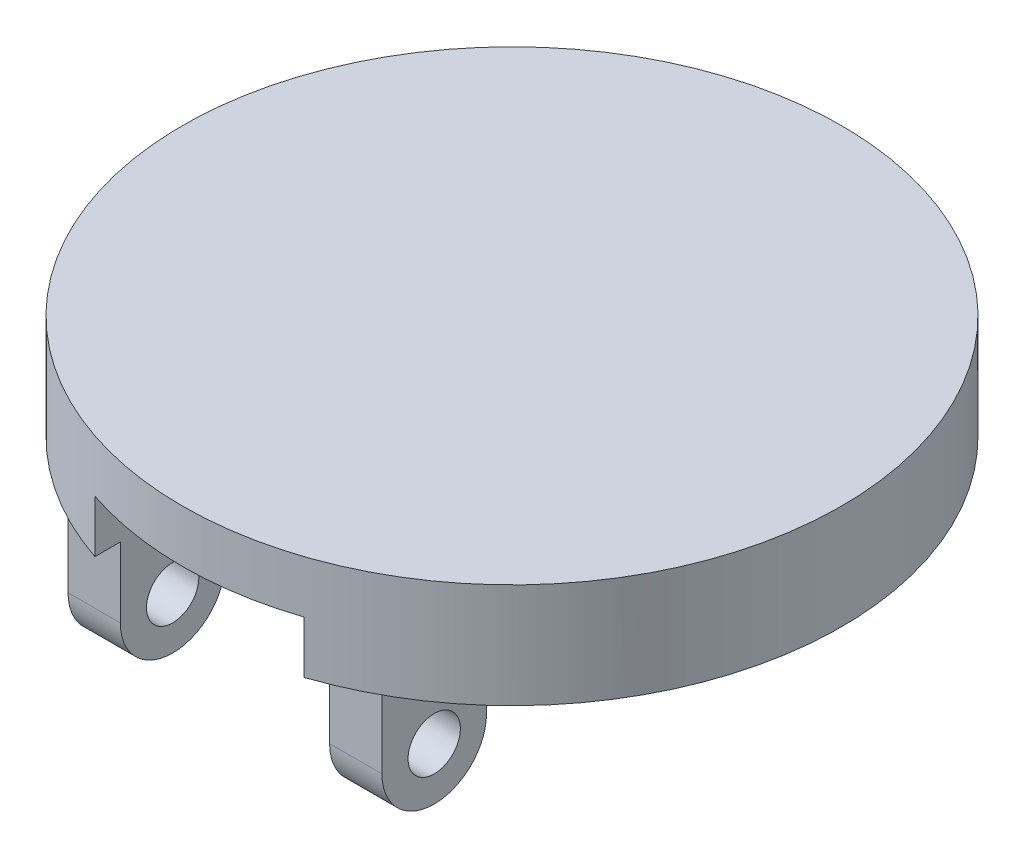
from build123d import *

# Parameters (mm, degrees)
SKETCH1_R           = 20.000000005
BOSS_EXTRUDE1_DEPTH = 6.35
BOSS_EXTRUDE2_DEPTH = 3.175
SKETCH3_R           = 1.5875
CUT_EXTRUDE1_DEPTH  = 30.525000005
CUT_EXTRUDE2_DEPTH  = 3.175


with BuildPart() as part:
    # Sketch1 → Boss-Extrude1 (new body)
    with BuildSketch(Plane(origin=(0, 0, 0), x_dir=(1, 0, 0), z_dir=(0, 1, 0))):
        Circle(SKETCH1_R)
    extrude(amount=BOSS_EXTRUDE1_DEPTH)

    # Sketch2 → Boss-Extrude2 (add)
    with BuildSketch(Plane(origin=(6.35, 0, 0), x_dir=(0, 0, -1), z_dir=(1, 0, 0))):
        with BuildLine():
            Line((-17.420082718, 0), (-17.420082718, -4.254))
            ThreePointArc((-17.420082718, -4.254), (-14.245082718, -7.429), (-11.070082718, -4.254))
            Line((-11.070082718, -4.254), (-11.070082718, -3.175))
            ThreePointArc((-11.070082718, -3.175), (-10.140146748, -0.92993597), (-7.895082718, 0))
            Line((-7.895082718, 0), (-5.849160659, 0))
            Line((-5.849160659, 0), (-5.849160659, 6.35))
            Line((-5.849160659, 6.35), (-11.070082718, 6.35))
            ThreePointArc((-11.070082718, 6.35), (-15.560210778, 4.490128061), (-17.420082718, 0))
        make_face()
    boss_extrude2 = extrude(amount=BOSS_EXTRUDE2_DEPTH)

    # Mirror1: Boss-Extrude2 across plane
    add(boss_extrude2.mirror(Plane(origin=(0, 0, 0), x_dir=(0, 0, 1), z_dir=(1, 0, 0))))

    # Sketch3 → Cut-Extrude1 (cut, through all)
    with BuildSketch(Plane(origin=(9.525, 0, 0), x_dir=(0, 0, -1), z_dir=(1, 0, 0))):
        with Locations((-14.245082718, -4.254)):
            Circle(SKETCH3_R)
    extrude(amount=-CUT_EXTRUDE1_DEPTH, mode=Mode.SUBTRACT)

    # Sketch5 → Cut-Extrude2 (cut)
    with BuildSketch(Plane.XZ):
        with BuildLine():
            Line((6.35, 18.965165441), (6.35, 7.605609073))
            ThreePointArc((6.35, 7.605609073), (0, -9.907965955), (-6.35, 7.605609073))
            Line((-6.35, 7.605609073), (-6.35, 18.965165441))
            ThreePointArc((-6.35, 18.965165441), (0, 20.000000005), (6.35, 18.965165441))
        make_face()
    extrude(amount=-CUT_EXTRUDE2_DEPTH, mode=Mode.SUBTRACT)


solid = part.part
